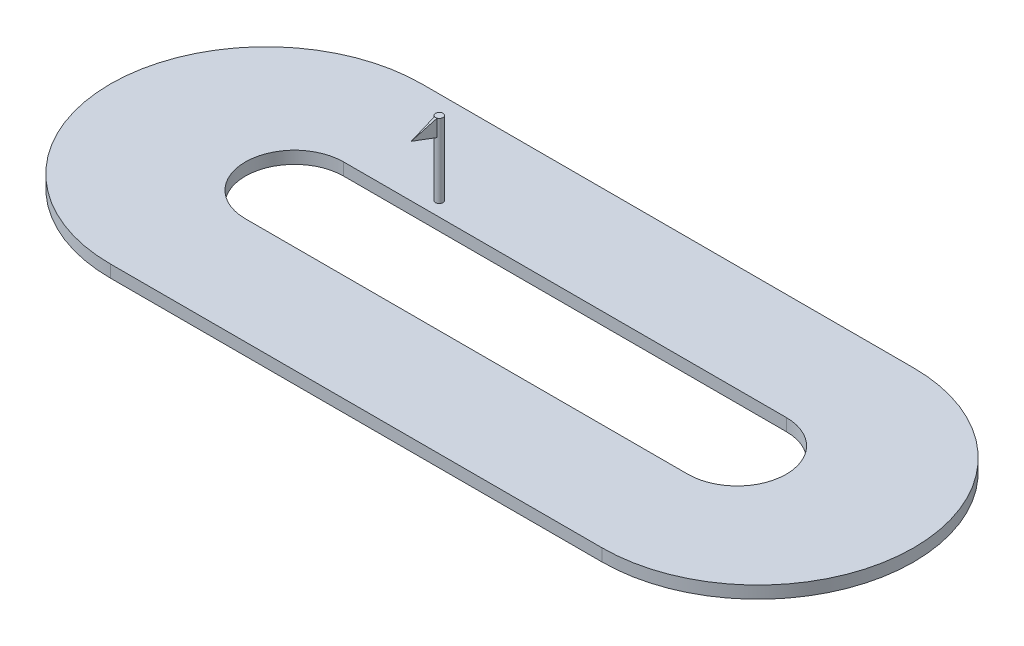
from build123d import *

# Parameters (mm, degrees)
BOSS_EXTRUDE1_DEPTH = 500
SKETCH5_R           = 150.634589438
BOSS_EXTRUDE4_DEPTH = 3000
SKETCH6_W           = 104.247390594
SKETCH6_H           = 680.109536147
BOSS_EXTRUDE5_DEPTH = 1000
BOSS_EXTRUDE5_TAPER = 3
CUT_EXTRUDE1_DEPTH  = 1000
SKETCH9_W           = 104.247390594
SKETCH9_H           = 680.109536147
BOSS_EXTRUDE6_DEPTH = 50


with BuildPart() as part:
    # Sketch1 → Boss-Extrude1 (new body)
    with BuildSketch(Plane(origin=(0, 0, 0), x_dir=(1, 0, 0), z_dir=(0, 1, 0))):
        with BuildLine():
            Line((-6645.600859059, 3345.311870775), (13354.399140941, 3345.311870775))
            ThreePointArc((13354.399140941, 3345.311870775), (19691.353441646, -2991.642429929), (13354.399140941, -9328.596730634))
            Line((13354.399140941, -9328.596730634), (-6645.600859059, -9328.596730634))
            ThreePointArc((-6645.600859059, -9328.596730634), (-12982.555159763, -2991.642429929), (-6645.600859059, 3345.311870775))
        make_face()
        with BuildLine():
            Line((-5491.594317378, -991.642429929), (12508.405682622, -991.642429929))
            ThreePointArc((12508.405682622, -991.642429929), (14508.405682622, -2991.642429929), (12508.405682622, -4991.642429929))
            Line((12508.405682622, -4991.642429929), (-5491.594317378, -4991.642429929))
            ThreePointArc((-5491.594317378, -4991.642429929), (-7491.594317378, -2991.642429929), (-5491.594317378, -991.642429929))
        make_face(mode=Mode.SUBTRACT)
    extrude(amount=BOSS_EXTRUDE1_DEPTH)

    # Sketch5 → Boss-Extrude4 (add)
    with BuildSketch(Plane(origin=(0, 500, 0), x_dir=(1, 0, 0), z_dir=(0, 1, 0))):
        with Locations((-2186.382335194, -408.689063218)):
            Circle(SKETCH5_R)
    extrude(amount=BOSS_EXTRUDE4_DEPTH)



with BuildPart() as body_2:
    # Sketch6 → Boss-Extrude5 (new body)
    with BuildSketch(Plane.XY.offset(559.323652656)):
        with Locations((-2184.332083006, 3159.945231927)):
            Rectangle(SKETCH6_W, SKETCH6_H)
    extrude(amount=BOSS_EXTRUDE5_DEPTH, taper=BOSS_EXTRUDE5_TAPER)

    # Sketch8 → Cut-Extrude1 (cut)
    with BuildSketch(Plane(origin=(-2035.747745755, 0, 0), x_dir=(0, 0, -1), z_dir=(1, 0, 0))):
        Polygon((-559.323652656, 3500), (-1553.903007293, 3447.876304703), (-1553.903007293, 3159.945231926), align=None)
        Polygon((-1553.903007293, 2872.01415915), (-1553.903007293, 3159.945231926), (-559.323652656, 2819.890463853), align=None)
    extrude(amount=-CUT_EXTRUDE1_DEPTH, mode=Mode.SUBTRACT)


with BuildPart() as part_1:
    add(part.part)

    add(body_2.part)  # Boss-Extrude6 merges body 2
    # Sketch9 → Boss-Extrude6 (add)
    with BuildSketch(Plane(origin=(0, 0, 559.323652656), x_dir=(-1, 0, 0), z_dir=(0, 0, -1))):
        with Locations((2184.332083006, 3159.945231927)):
            Rectangle(SKETCH9_W, SKETCH9_H)
    extrude(amount=BOSS_EXTRUDE6_DEPTH)


solid = part_1.part
